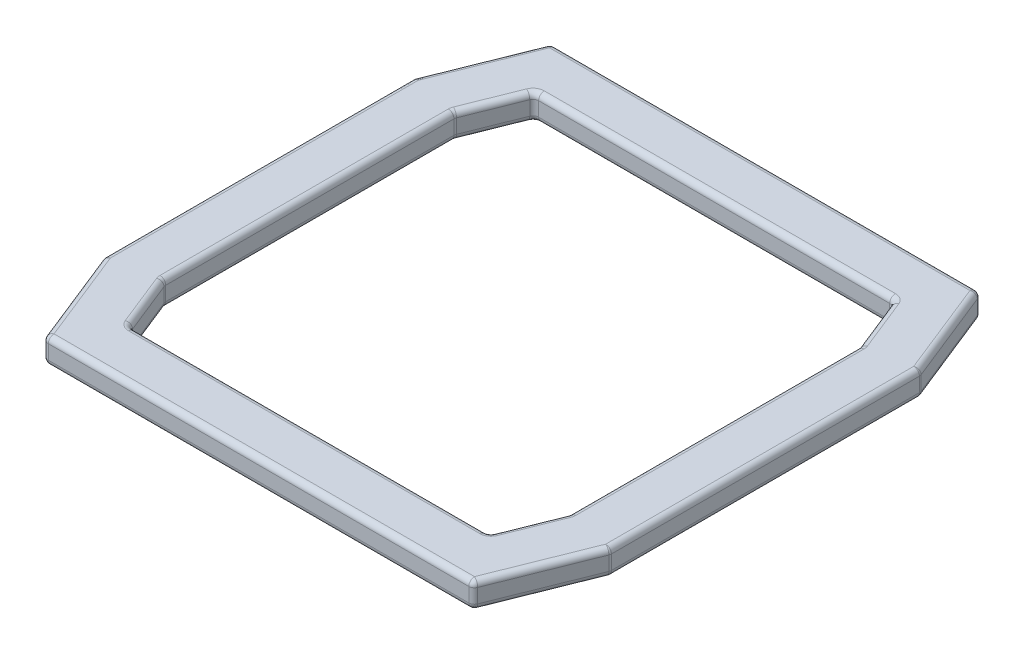
from build123d import *

# Parameters (mm, degrees)
BOSS_EXTRUDE1_DEPTH = 2.25
FILLET1_R           = 1


with BuildPart() as part:
    # Sketch1 → Boss-Extrude1 (new body, symmetric)
    with BuildSketch(Plane(origin=(0, 0, 0), x_dir=(1, 0, 0), z_dir=(0, 1, 0))):
        Polygon((-37.593296653, -44.5), (37.593296653, -44.5), (44.5, -27.233241632), (44.5, 27.233241632), (37.593296653, 44.5), (-37.593296653, 44.5), (-44.5, 27.233241632), (-44.5, -27.233241632), align=None)
        Polygon((-31.5, -35.5), (31.5, -35.5), (35.5, -25.5), (35.5, 25.5), (31.5, 35.5), (-31.5, 35.5), (-35.5, 25.5), (-35.5, -25.5), align=None, mode=Mode.SUBTRACT)
    extrude(amount=BOSS_EXTRUDE1_DEPTH, both=True)

    # Fillet1
    fillet1_edges = [part.edges().sort_by_distance(p)[0] for p in [
        (44.5, -2.25, 0),
        (41.046648326, -2.25, 35.866620816),
        (0, -2.25, 44.5),
        (-41.046648326, -2.25, 35.866620816),
        (41.046648326, 2.25, 35.866620816),
        (-44.5, 0, 27.233241632),
        (-44.5, 0, -27.233241632),
        (-37.593296653, 0, -44.5),
        (37.593296653, 0, -44.5),
        (44.5, 0, -27.233241632),
        (44.5, 0, 27.233241632),
        (37.593296653, 0, 44.5),
        (-37.593296653, 0, 44.5),
        (44.5, 2.25, 0),
        (41.046648326, 2.25, -35.866620816),
        (0, 2.25, -44.5),
        (33.5, -2.25, -30.5),
        (35.5, 0, -25.5),
        (0, -2.25, -35.5),
        (31.5, 0, -35.5),
        (-33.5, -2.25, -30.5),
        (-31.5, 0, -35.5),
        (-35.5, -2.25, 0),
        (-41.046648326, 2.25, -35.866620816),
        (-35.5, 0, -25.5),
        (-33.5, -2.25, 30.5),
        (-35.5, 0, 25.5),
        (0, -2.25, 35.5),
        (-31.5, 0, 35.5),
        (33.5, -2.25, 30.5),
        (31.5, 0, 35.5),
        (35.5, -2.25, 0),
        (35.5, 0, 25.5),
        (33.5, 2.25, -30.5),
        (0, 2.25, -35.5),
        (-33.5, 2.25, -30.5),
        (-35.5, 2.25, 0),
        (-33.5, 2.25, 30.5),
        (0, 2.25, 35.5),
        (33.5, 2.25, 30.5),
        (-44.5, 2.25, 0),
        (35.5, 2.25, 0),
        (-41.046648326, 2.25, 35.866620816),
        (-44.5, -2.25, 0),
        (0, 2.25, 44.5),
        (-41.046648326, -2.25, -35.866620816),
        (0, -2.25, -44.5),
        (41.046648326, -2.25, -35.866620816),
    ]]
    fillet(fillet1_edges, radius=FILLET1_R)


solid = part.part
